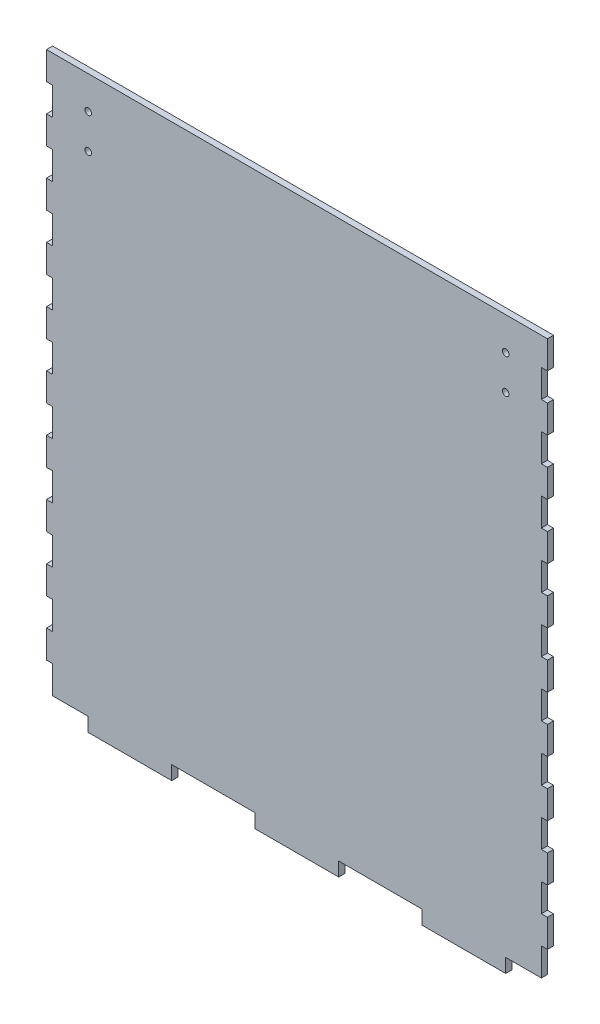
from build123d import *

# Parameters (mm, degrees)
BOSS_EXTRUDE1_DEPTH = 2.778125
SKETCH2_R           = 1.5
CUT_EXTRUDE1_DEPTH  = 2.778125


with BuildPart() as part:
    # Sketch1 → Boss-Extrude1 (new body)
    with BuildSketch(Plane.XY):
        Polygon((-114.3, 127), (-114.3, 114.3), (-111.521875, 114.3), (-111.521875, 101.6), (-114.3, 101.6), (-114.3, 88.9), (-111.521875, 88.9), (-111.521875, 76.2), (-114.3, 76.2), (-114.3, 63.5), (-111.521875, 63.5), (-111.521875, 50.8), (-114.3, 50.8), (-114.3, 38.1), (-111.521875, 38.1), (-111.521875, 25.4), (-114.3, 25.4), (-114.3, 12.7), (-111.521875, 12.7), (-111.521875, 0), (-114.3, 0), (-114.3, -12.7), (-111.521875, -12.7), (-111.521875, -25.4), (-114.3, -25.4), (-114.3, -38.1), (-111.521875, -38.1), (-111.521875, -50.8), (-114.3, -50.8), (-114.3, -63.5), (-111.521875, -63.5), (-111.521875, -76.2), (-114.3, -76.2), (-114.3, -88.9), (-111.521875, -88.9), (-111.521875, -101.6), (-114.3, -101.6), (-114.3, -114.3), (-111.521875, -114.3), (-111.521875, -127), (-95.25, -127), (-95.25, -133.35), (-57.15, -133.35), (-57.15, -127), (-19.05, -127), (-19.05, -133.35), (19.05, -133.35), (19.05, -127), (57.15, -127), (57.15, -133.35), (95.25, -133.35), (95.25, -127), (111.521875, -127), (111.521875, -114.3), (114.3, -114.3), (114.3, -101.6), (111.521875, -101.6), (111.521875, -88.9), (114.3, -88.9), (114.3, -76.2), (111.521875, -76.2), (111.521875, -63.5), (114.3, -63.5), (114.3, -50.8), (111.521875, -50.8), (111.521875, -38.1), (114.3, -38.1), (114.3, -25.4), (111.521875, -25.4), (111.521875, -12.7), (114.3, -12.7), (114.3, 0), (111.521875, 0), (111.521875, 12.7), (114.3, 12.7), (114.3, 25.4), (111.521875, 25.4), (111.521875, 38.1), (114.3, 38.1), (114.3, 50.8), (111.521875, 50.8), (111.521875, 63.5), (114.3, 63.5), (114.3, 76.2), (111.521875, 76.2), (111.521875, 88.9), (114.3, 88.9), (114.3, 101.6), (111.521875, 101.6), (111.521875, 114.3), (114.3, 114.3), (114.3, 127), align=None)
    extrude(amount=BOSS_EXTRUDE1_DEPTH)

    # Sketch2 → Cut-Extrude1 (cut)
    with BuildSketch(Plane(origin=(0, 0, 0), x_dir=(-1, 0, 0), z_dir=(0, 0, -1))):
        with Locations((-95.25, 112)):
            Circle(SKETCH2_R)
        with Locations((-95.25, 96.25)):
            Circle(SKETCH2_R)
        with Locations((95.25, 96.25)):
            Circle(SKETCH2_R)
        with Locations((95.25, 112)):
            Circle(SKETCH2_R)
    extrude(amount=-CUT_EXTRUDE1_DEPTH, mode=Mode.SUBTRACT)


solid = part.part
